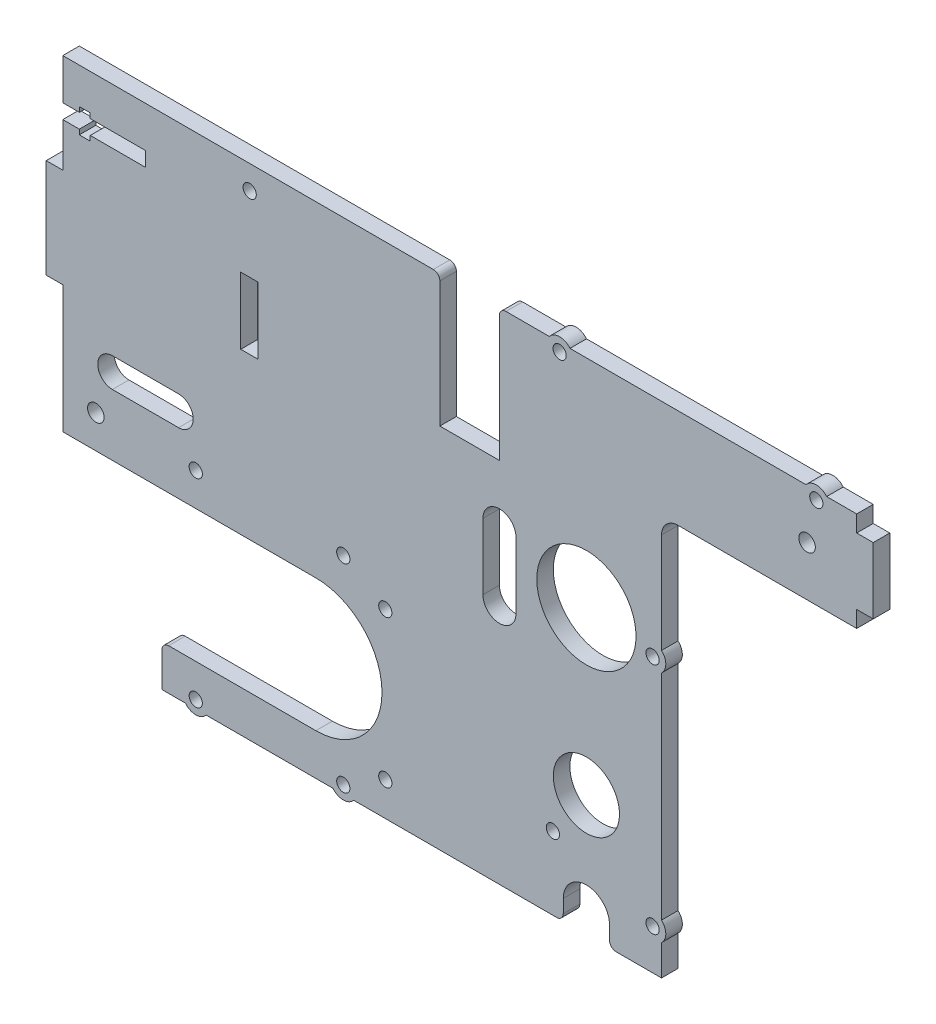
from build123d import *

# Parameters (mm, degrees)
SKETCH1_W                = 240
SKETCH1_H                = 151
BOSS_EXTRUDE1_DEPTH      = 5
SKETCH5_R                = 2
CUT_EXTRUDE1_DEPTH       = 5
SKETCH6_R                = 4
SKETCH6_R_2              = 2
BOSS_EXTRUDE2_DEPTH      = 5
CUT_EXTRUDE2_DEPTH       = 5
SKETCH8_W                = 30
SKETCH8_H                = 12.5
CUT_EXTRUDE3_DEPTH       = 5
SKETCH9_W                = 59
SKETCH9_H                = 121
CUT_EXTRUDE4_DEPTH       = 5
SKETCH12_W               = 18
SKETCH12_H               = 40
CUT_EXTRUDE7_DEPTH       = 10
SKETCH13_R               = 2
CUT_EXTRUDE8_DEPTH       = 10
SKETCH15_R               = 2
CUT_EXTRUDE9_DEPTH       = 5
SKETCH16_W               = 5.2
SKETCH16_H               = 20.2
CUT_EXTRUDE10_DEPTH      = 5
SKETCH17_R               = 4
SKETCH17_R_2             = 2
BOSS_EXTRUDE3_DEPTH      = 5
CUT_EXTRUDE11_DEPTH      = 10
SKETCH19_R               = 15
CUT_EXTRUDE12_DEPTH      = 10
CUT_EXTRUDE13_DEPTH      = 1
CUT_EXTRUDE13_DEPTH_BACK = 10
SKETCH23_R               = 2
CUT_EXTRUDE16_DEPTH      = 5
SKETCH24_R               = 4
SKETCH24_R_2             = 2
BOSS_EXTRUDE4_DEPTH      = 5
SKETCH27_R               = 2.5
CUT_EXTRUDE18_DEPTH      = 10
CUT_EXTRUDE19_DEPTH      = 10
SKETCH31_R               = 2.5
CUT_EXTRUDE20_DEPTH      = 10
SKETCH32_W               = 5
SKETCH32_H               = 30
SKETCH32_H_2             = 20
BOSS_EXTRUDE6_DEPTH      = 5
FILLET1_R                = 5
FILLET2_R                = 2
CUT_EXTRUDE22_DEPTH      = 5
SKETCH35_R               = 10
CUT_EXTRUDE23_DEPTH      = 5
SKETCH36_R               = 2
CUT_EXTRUDE24_DEPTH      = 5


with BuildPart() as part:
    # Sketch1 → Boss-Extrude1 (new body)
    with BuildSketch(Plane.XY):
        Rectangle(SKETCH1_W, SKETCH1_H)
    extrude(amount=BOSS_EXTRUDE1_DEPTH)

    # Sketch5 → Cut-Extrude1 (cut)
    with BuildSketch(Plane(origin=(0, 0, 0), x_dir=(-1, 0, 0), z_dir=(0, 0, -1))):
        with Locations((35.2, -73)):
            Circle(SKETCH5_R)
        with Locations((79.8, -73)):
            Circle(SKETCH5_R)
        with Locations((22.5, -65.3)):
            Circle(SKETCH5_R)
        with Locations((22.5, -20.7)):
            Circle(SKETCH5_R)
        with Locations((79.8, -13)):
            Circle(SKETCH5_R)
        with Locations((35.2, -13)):
            Circle(SKETCH5_R)
    extrude(amount=-CUT_EXTRUDE1_DEPTH, mode=Mode.SUBTRACT)

    # Sketch6 → Boss-Extrude2 (add)
    with BuildSketch(Plane(origin=(0, 0, 0), x_dir=(-1, 0, 0), z_dir=(0, 0, -1))):
        with Locations((35.2, -73)):
            Circle(SKETCH6_R)
        with Locations((35.2, -73)):
            Circle(SKETCH6_R_2, mode=Mode.SUBTRACT)
        with Locations((79.8, -73)):
            Circle(SKETCH6_R)
        with Locations((79.8, -73)):
            Circle(SKETCH6_R_2, mode=Mode.SUBTRACT)
    extrude(amount=-BOSS_EXTRUDE2_DEPTH)

    # Sketch7 → Cut-Extrude2 (cut)
    with BuildSketch(Plane(origin=(0, 0, 0), x_dir=(-1, 0, 0), z_dir=(0, 0, -1))):
        with BuildLine():
            Line((120, -63), (43.5, -63))
            ThreePointArc((43.5, -63), (23.5, -43), (43.5, -23))
            Line((43.5, -23), (120, -23))
            Line((120, -23), (120, -63))
        make_face()
    extrude(amount=-CUT_EXTRUDE2_DEPTH, mode=Mode.SUBTRACT)

    # Sketch8 → Cut-Extrude3 (cut)
    with BuildSketch(Plane(origin=(0, 0, 0), x_dir=(-1, 0, 0), z_dir=(0, 0, -1))):
        with Locations((105, -69.25)):
            Rectangle(SKETCH8_W, SKETCH8_H)
    extrude(amount=-CUT_EXTRUDE3_DEPTH, mode=Mode.SUBTRACT)

    # Sketch9 → Cut-Extrude4 (cut)
    with BuildSketch(Plane(origin=(0, 0, 0), x_dir=(-1, 0, 0), z_dir=(0, 0, -1))):
        with Locations((-90.5, -15)):
            Rectangle(SKETCH9_W, SKETCH9_H)
    extrude(amount=-CUT_EXTRUDE4_DEPTH, mode=Mode.SUBTRACT)

    # Sketch12 → Cut-Extrude7 (cut)
    with BuildSketch(Plane(origin=(0, 0, 0), x_dir=(-1, 0, 0), z_dir=(0, 0, -1))):
        with Locations((-3, 55.5)):
            Rectangle(SKETCH12_W, SKETCH12_H)
    extrude(amount=-CUT_EXTRUDE7_DEPTH, mode=Mode.SUBTRACT)

    # Sketch13 → Cut-Extrude8 (cut)
    with BuildSketch(Plane(origin=(0, 0, 0), x_dir=(-1, 0, 0), z_dir=(0, 0, -1))):
        with Locations((-58.295562695, 7.3)):
            Circle(SKETCH13_R)
        with Locations((-58.295562695, -63.3)):
            Circle(SKETCH13_R)
    extrude(amount=-CUT_EXTRUDE8_DEPTH, mode=Mode.SUBTRACT)

    # Sketch15 → Cut-Extrude9 (cut)
    with BuildSketch(Plane.XY.offset(5)):
        with Locations((-63.5, 68.3)):
            Circle(SKETCH15_R)
    extrude(amount=-CUT_EXTRUDE9_DEPTH, mode=Mode.SUBTRACT)

    # Sketch16 → Cut-Extrude10 (cut)
    with BuildSketch(Plane(origin=(0, 0, 0), x_dir=(-1, 0, 0), z_dir=(0, 0, -1))):
        with Locations((63.6, 35.6)):
            Rectangle(SKETCH16_W, SKETCH16_H)
    extrude(amount=-CUT_EXTRUDE10_DEPTH, mode=Mode.SUBTRACT)

    # Sketch17 → Boss-Extrude3 (add)
    with BuildSketch(Plane(origin=(0, 0, 0), x_dir=(-1, 0, 0), z_dir=(0, 0, -1))):
        with Locations((-58.295562695, 7.3)):
            Circle(SKETCH17_R)
        with Locations((-58.295562695, 7.3)):
            Circle(SKETCH17_R_2, mode=Mode.SUBTRACT)
        with Locations((-58.295562695, -63.3)):
            Circle(SKETCH17_R)
        with Locations((-58.295562695, -63.3)):
            Circle(SKETCH17_R_2, mode=Mode.SUBTRACT)
    extrude(amount=-BOSS_EXTRUDE3_DEPTH)

    # Sketch18 → Cut-Extrude11 (cut)
    with BuildSketch(Plane(origin=(0, 0, 0), x_dir=(-1, 0, 0), z_dir=(0, 0, -1))):
        with BuildLine():
            Line((-7.007007892, 17.8501367), (-7.007007892, -2.1498633))
            ThreePointArc((-7.007007892, -2.1498633), (-12.007007892, -7.1498633), (-17.007007892, -2.1498633))
            Line((-17.007007892, -2.1498633), (-17.007007892, 17.8501367))
            ThreePointArc((-17.007007892, 17.8501367), (-12.007007892, 22.8501367), (-7.007007892, 17.8501367))
        make_face()
    extrude(amount=-CUT_EXTRUDE11_DEPTH, mode=Mode.SUBTRACT)

    # Sketch19 → Cut-Extrude12 (cut)
    with BuildSketch(Plane(origin=(0, 0, 0), x_dir=(-1, 0, 0), z_dir=(0, 0, -1))):
        with Locations((-38.295562695, 10.103446171)):
            Circle(SKETCH19_R)
    extrude(amount=-CUT_EXTRUDE12_DEPTH, mode=Mode.SUBTRACT)

    # Sketch20 → Cut-Extrude13 (cut, two sides)
    with BuildSketch(Plane(origin=(0, 0, 0), x_dir=(-1, 0, 0), z_dir=(0, 0, -1))) as cut_extrude13_sk:
        with BuildLine():
            ThreePointArc((-31.295562695, -69.5), (-38.295562695, -62.5), (-45.295562695, -69.5))
            Line((-45.295562695, -69.5), (-45.295562695, -75.5))
            Line((-45.295562695, -75.5), (-31.295562695, -75.5))
            Line((-31.295562695, -75.5), (-31.295562695, -69.5))
        make_face()
    extrude(amount=CUT_EXTRUDE13_DEPTH, mode=Mode.SUBTRACT)
    extrude(cut_extrude13_sk.sketch, amount=-CUT_EXTRUDE13_DEPTH_BACK, mode=Mode.SUBTRACT)

    # Sketch23 → Cut-Extrude16 (cut)
    with BuildSketch(Plane(origin=(0, 0, 0), x_dir=(-1, 0, 0), z_dir=(0, 0, -1))):
        with Locations((-107.8, 73)):
            Circle(SKETCH23_R)
        with Locations((-30.2, 73)):
            Circle(SKETCH23_R)
    extrude(amount=-CUT_EXTRUDE16_DEPTH, mode=Mode.SUBTRACT)

    # Sketch24 → Boss-Extrude4 (add)
    with BuildSketch(Plane(origin=(0, 0, 0), x_dir=(-1, 0, 0), z_dir=(0, 0, -1))):
        with Locations((-107.8, 73)):
            Circle(SKETCH24_R)
        with Locations((-107.8, 73)):
            Circle(SKETCH24_R_2, mode=Mode.SUBTRACT)
        with Locations((-30.2, 73)):
            Circle(SKETCH24_R)
        with Locations((-30.2, 73)):
            Circle(SKETCH24_R_2, mode=Mode.SUBTRACT)
    extrude(amount=-BOSS_EXTRUDE4_DEPTH)

    # Sketch27 → Cut-Extrude18 (cut)
    with BuildSketch(Plane(origin=(0, 0, 0), x_dir=(-1, 0, 0), z_dir=(0, 0, -1))):
        with Locations((110, -13)):
            Circle(SKETCH27_R)
    extrude(amount=-CUT_EXTRUDE18_DEPTH, mode=Mode.SUBTRACT)

    # Sketch30 → Cut-Extrude19 (cut)
    with BuildSketch(Plane(origin=(0, 0, 0), x_dir=(-1, 0, 0), z_dir=(0, 0, -1))):
        with BuildLine():
            Line((105, -4.424095919), (85, -4.424095919))
            ThreePointArc((85, -4.424095919), (80.575904081, 0), (85, 4.424095919))
            Line((85, 4.424095919), (105, 4.424095919))
            ThreePointArc((105, 4.424095919), (109.424095919, 0), (105, -4.424095919))
        make_face()
    extrude(amount=-CUT_EXTRUDE19_DEPTH, mode=Mode.SUBTRACT)

    # Sketch31 → Cut-Extrude20 (cut)
    with BuildSketch(Plane(origin=(0, 0, 0), x_dir=(-1, 0, 0), z_dir=(0, 0, -1))):
        with Locations((-105, 60.5)):
            Circle(SKETCH31_R)
    extrude(amount=-CUT_EXTRUDE20_DEPTH, mode=Mode.SUBTRACT)

    # Sketch32 → Boss-Extrude6 (add)
    with BuildSketch(Plane(origin=(0, 0, 0), x_dir=(-1, 0, 0), z_dir=(0, 0, -1))):
        with Locations((122.5, 30.5)):
            Rectangle(SKETCH32_W, SKETCH32_H)
        with Locations((-122.5, 60.5)):
            Rectangle(SKETCH32_W, SKETCH32_H_2)
    extrude(amount=-BOSS_EXTRUDE6_DEPTH)

    # Fillet1
    fillet1_edges = [part.edges().sort_by_distance(p)[0] for p in [
        (61, 45.5, 2.5),
    ]]
    fillet(fillet1_edges, radius=FILLET1_R)

    # Fillet2
    fillet2_edges = [part.edges().sort_by_distance(p)[0] for p in [
        (12, 75.5, 2.5),
        (-6, 75.5, 2.5),
        (31.295562695, -75.5, 2.5),
        (45.295562695, -75.5, 2.5),
        (-90, -63, 2.5),
    ]]
    fillet(fillet2_edges, radius=FILLET2_R)

    # Sketch34 → Cut-Extrude22 (cut)
    with BuildSketch(Plane(origin=(0, 0, 0), x_dir=(-1, 0, 0), z_dir=(0, 0, -1))):
        Polygon((115, 58.736739195), (120, 58.736739195), (120, 63.136739195), (115, 63.136739195), (115, 64.636739195), (111.7, 64.636739195), (111.7, 63.136739195), (95, 63.136739195), (95, 58.736739195), (111.7, 58.736739195), (111.7, 57.236739195), (115, 57.236739195), align=None)
    extrude(amount=-CUT_EXTRUDE22_DEPTH, mode=Mode.SUBTRACT)

    # Sketch35 → Cut-Extrude23 (cut)
    with BuildSketch(Plane(origin=(0, 0, 0), x_dir=(-1, 0, 0), z_dir=(0, 0, -1))):
        with Locations((-38.295562695, -38.978399319)):
            Circle(SKETCH35_R)
    extrude(amount=-CUT_EXTRUDE23_DEPTH, mode=Mode.SUBTRACT)

    # Sketch36 → Cut-Extrude24 (cut)
    with BuildSketch(Plane(origin=(0, 0, 0), x_dir=(-1, 0, 0), z_dir=(0, 0, -1))):
        with Locations((-28.16035742, -53.440416767)):
            Circle(SKETCH36_R)
    extrude(amount=-CUT_EXTRUDE24_DEPTH, mode=Mode.SUBTRACT)


solid = part.part
